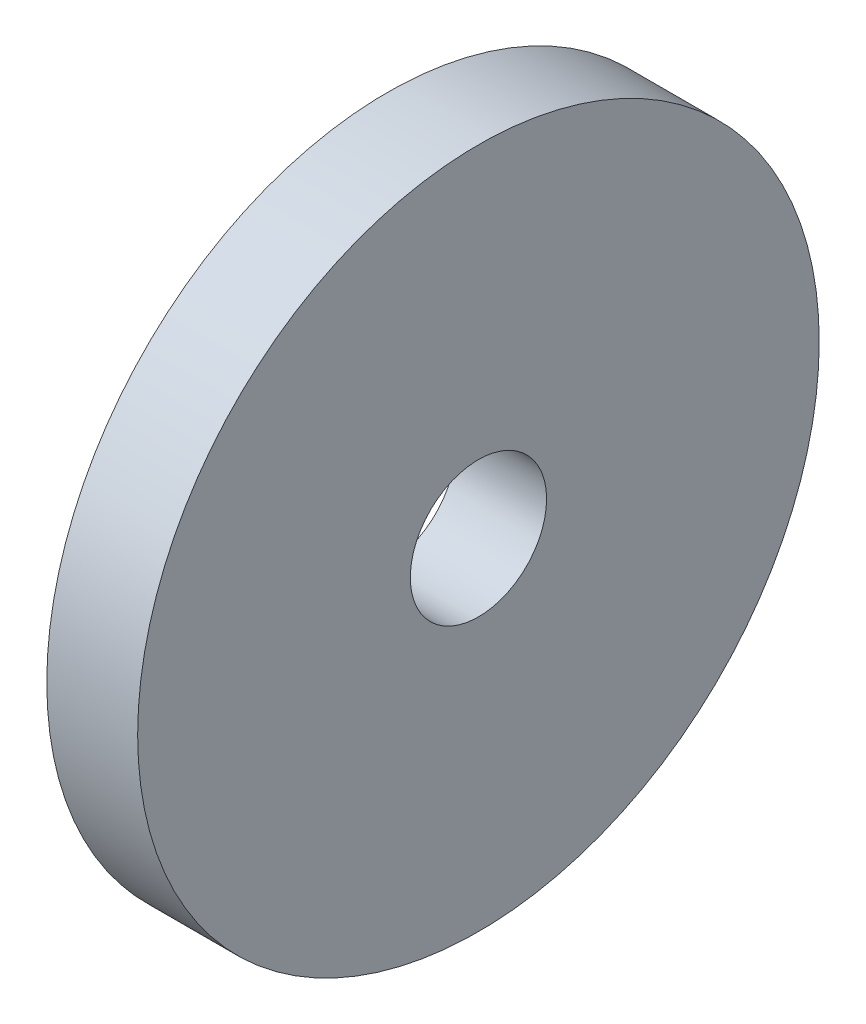
from build123d import *

# Parameters (mm, degrees)
SKETCH1_R           = 7.5
BOSS_EXTRUDE1_DEPTH = 2
SKETCH2_R           = 1.5
CUT_EXTRUDE1_DEPTH  = 3


with BuildPart() as part:
    # Sketch1 → Boss-Extrude1 (new body)
    with BuildSketch(Plane(origin=(0, 0, 0), x_dir=(0, 0, -1), z_dir=(1, 0, 0))):
        Circle(SKETCH1_R)
    extrude(amount=BOSS_EXTRUDE1_DEPTH)

    # Sketch2 → Cut-Extrude1 (cut, through all)
    with BuildSketch(Plane(origin=(2, 0, 0), x_dir=(0, 0, -1), z_dir=(1, 0, 0))):
        Circle(SKETCH2_R)
    extrude(amount=-CUT_EXTRUDE1_DEPTH, mode=Mode.SUBTRACT)


solid = part.part
